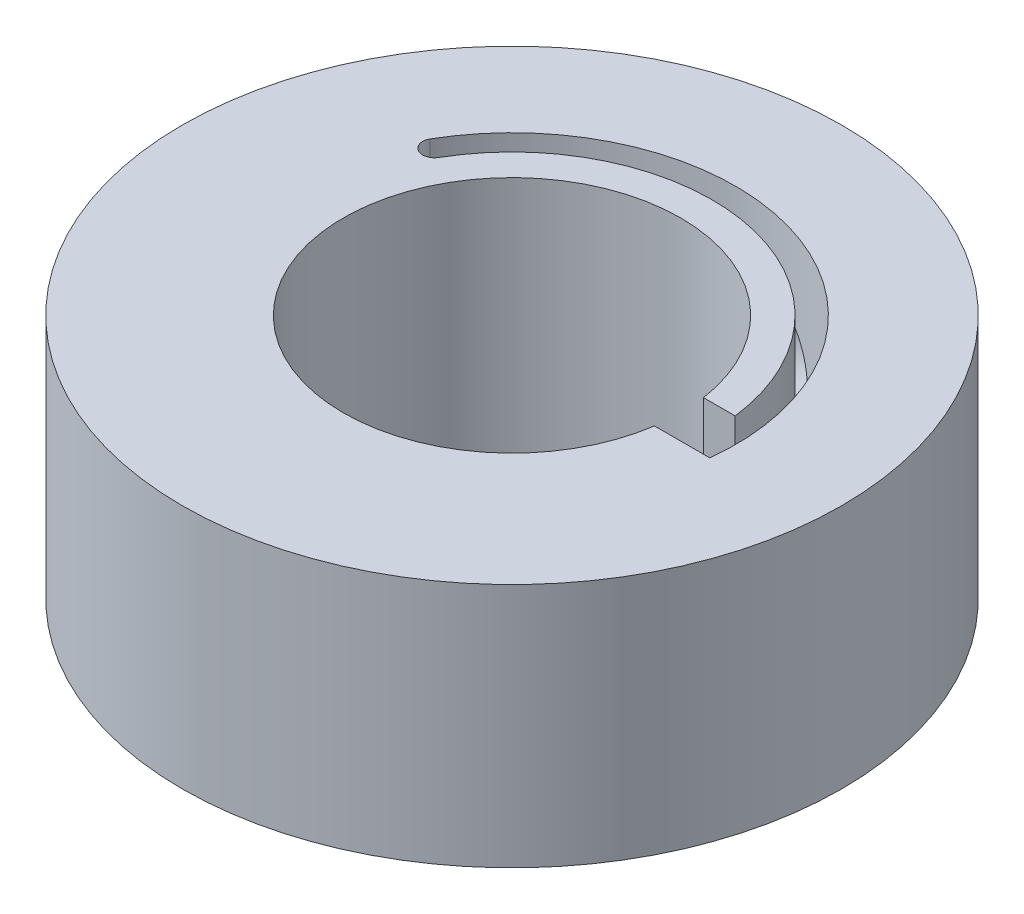
from build123d import *

# Parameters (mm, degrees)
SKETCH1_R           = 21.336
BOSS_EXTRUDE1_DEPTH = 7.9375


with BuildPart() as part:
    # Sketch1 → Boss-Extrude1 (new body, symmetric)
    with BuildSketch(Plane(origin=(0, 0, 0), x_dir=(1, 0, 0), z_dir=(0, 1, 0))):
        Circle(SKETCH1_R)
        with BuildLine():
            Line((10.806013499, 1.5875), (12.856358728, 1.5875))
            ThreePointArc((12.856358728, 1.5875), (2.578265605, 12.694828178), (-11.218493081, 6.477))
            ThreePointArc((-11.218493081, 6.477), (-12.259404438, 6.198088642), (-12.538315796, 7.239))
            ThreePointArc((-12.538315796, 7.239), (4.50939131, 13.757829553), (14.390702823, -1.5875))
            Line((14.390702823, -1.5875), (10.806013499, -1.5875))
            ThreePointArc((10.806013499, -1.5875), (-10.922, 0), (10.806013499, 1.5875))
        make_face(mode=Mode.SUBTRACT)
    extrude(amount=BOSS_EXTRUDE1_DEPTH, both=True)

    # Sketch2 → Cut-Revolve1 (revolve, cut)
    with BuildSketch(Plane(origin=(0, 0, 0), x_dir=(1, 0, 0), z_dir=(0, 1, 0))):
        Polygon((-0.300030586, 14.474890868), (2.811446909, 13.842963024), (4.246555115, 20.909128764), (1.13507762, 21.541056608), align=None)
    revolve(axis=Axis((2.811446909, 0, -13.842963024), (-0.199032392, 0, 0.979992912)), mode=Mode.SUBTRACT)


solid = part.part
